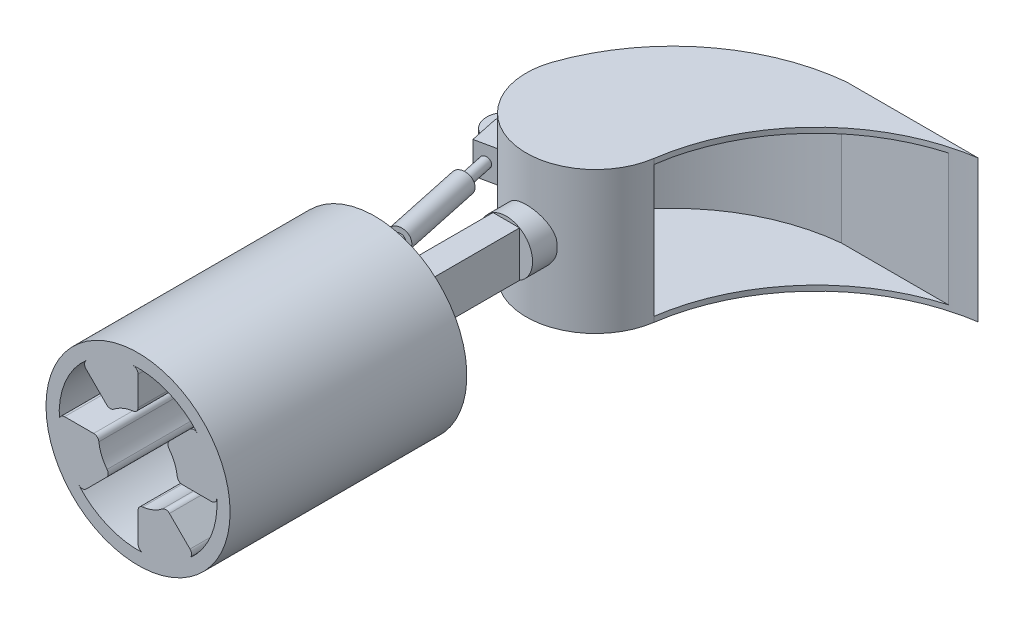
from build123d import *
from build123d.topology import SkipClean

# Parameters (mm, degrees)
BOSS_EXTRUDE1_DEPTH       = 2
BOSS_EXTRUDE2_START       = 50
BOSS_EXTRUDE2_DEPTH       = 50
BOSS_EXTRUDE3_START       = 2
BOSS_EXTRUDE3_DEPTH       = 2
SKETCH4_W                 = 9.387961781
SKETCH4_H                 = 10
SKETCH5_W                 = 10.07129112
SKETCH5_H                 = 17.27915204
BOSS_EXTRUDE4_DEPTH       = 50
BOSS_EXTRUDE5_DEPTH       = 7.5
BOSS_EXTRUDE5_DEPTH_BACK  = 7.5
CUT_EXTRUDE1_DEPTH        = 21.5
SKETCH8_R                 = 4
CUT_EXTRUDE2_DEPTH        = 21.5
SKETCH9_R                 = 35
BOSS_EXTRUDE7_DEPTH       = 90
SKETCH12_R                = 35
BOSS_EXTRUDE8_DEPTH       = 10
BOSS_EXTRUDE9_DEPTH       = 5
BOSS_EXTRUDE9_DEPTH_BACK  = 5
SKETCH13_R                = 4
BOSS_EXTRUDE10_DEPTH      = 1
BOSS_EXTRUDE10_DEPTH_BACK = 11


with BuildPart() as part:
    # Sketch1 → Boss-Extrude1 (new body)
    with BuildSketch(Plane(origin=(0, 0, 0), x_dir=(1, 0, 0), z_dir=(0, 1, 0))):
        with BuildLine():
            Line((37.497695016, 57.938362748), (87.497695016, 57.938362748))
            ThreePointArc((87.497695016, 57.938362748), (46.576317276, 37.244851113), (26.079739949, -3.775520627))
            ThreePointArc((26.079739949, -3.775520627), (-6.213319511, -25.608632381), (-24.910176653, 8.595957825))
            ThreePointArc((-24.910176653, 8.595957825), (-0.927644781, 42.400733173), (37.497695016, 57.938362748))
        make_face()
    extrude(amount=BOSS_EXTRUDE1_DEPTH)

    # Sketch2 → Boss-Extrude2 (add)
    with SkipClean():  # the faces are left unmerged after this step: merging them gives an invalid solid
        with BuildSketch(Plane.XZ.offset(BOSS_EXTRUDE2_START)):
            with BuildLine():
                Line((87.497695016, -57.938362748), (37.497695016, -57.938362748))
                ThreePointArc((37.497695016, -57.938362748), (-0.927644781, -42.400733173), (-24.910176653, -8.595957825))
                ThreePointArc((-24.910176653, -8.595957825), (-6.213319511, 25.608632381), (26.079739949, 3.775520627))
                Line((26.079739949, 3.775520627), (24.100374046, 3.488971114))
                ThreePointArc((24.100374046, 3.488971114), (-5.741749135, 23.665021983), (-23.019576731, -7.943553091))
                ThreePointArc((-23.019576731, -7.943553091), (0.27399215, -40.801176215), (37.597970133, -55.938362748))
                Line((37.597970133, -55.938362748), (78.265833112, -55.938362748))
                ThreePointArc((78.265833112, -55.938362748), (82.849368767, -57.087897202), (87.497695016, -57.938362748))
            make_face()
        extrude(amount=-BOSS_EXTRUDE2_DEPTH)

    # Sketch3 → Boss-Extrude3 (add)
    with SkipClean():  # the faces are left unmerged after this step: merging them gives an invalid solid
        with BuildSketch(Plane.XZ.offset(50).offset(BOSS_EXTRUDE3_START)):
            with BuildLine():
                Line((37.497695016, -57.938362748), (87.497695016, -57.938362748))
                ThreePointArc((87.497695016, -57.938362748), (82.849368767, -57.087897202), (78.265833112, -55.938362748))
                ThreePointArc((78.265833112, -55.938362748), (43.353130622, -33.789233028), (26.079739949, 3.775520627))
                ThreePointArc((26.079739949, 3.775520627), (-6.213319511, 25.608632381), (-24.910176653, -8.595957825))
                ThreePointArc((-24.910176653, -8.595957825), (-0.927644781, -42.400733173), (37.497695016, -57.938362748))
            make_face()
        extrude(amount=-BOSS_EXTRUDE3_DEPTH)

    # Sketch4 → Revolve1 (revolve)
    with SkipClean():  # the faces are left unmerged after this step: merging them gives an invalid solid
        with BuildSketch(Plane(origin=(0, 0, 0), x_dir=(0, 0, -1), z_dir=(1, 0, 0))):
            with Locations((-29.221177555, -30)):
                Rectangle(SKETCH4_W, SKETCH4_H)
        revolve(axis=Axis((0, -25, 24.527196664), (0, 0, 1)))

    # Sketch5 → Boss-Extrude4 (add)
    with SkipClean():  # the faces are left unmerged after this step: merging them gives an invalid solid
        with BuildSketch(Plane.XY.offset(33.915158445)):
            with Locations((0, -25)):
                Rectangle(SKETCH5_W, SKETCH5_H)
        extrude(amount=BOSS_EXTRUDE4_DEPTH)

    # Sketch6 → Boss-Extrude5 (add, two sides: drawn at the far end of the back side and taken through both)
    with SkipClean():  # the faces are left unmerged after this step: merging them gives an invalid solid
        with BuildSketch(Plane.XY.offset(-BOSS_EXTRUDE5_DEPTH_BACK)):
            Polygon((-41.351610801, -30), (-41.351610801, -20), (-26.351610801, -20), (-24.351610801, -20), (-24.351610801, -30), (-26.351610801, -30), align=None)
        extrude(amount=BOSS_EXTRUDE5_DEPTH + BOSS_EXTRUDE5_DEPTH_BACK)

    # Sketch7 → Cut-Extrude1 (cut)
    with SkipClean():  # the faces are left unmerged after this step: merging them gives an invalid solid
        with BuildSketch(Plane.XZ.offset(30)):
            with BuildLine():
                Line((-33.851610801, 7.5), (-42.709452284, 8.726443805))
                Line((-42.709452284, 8.726443805), (-44.053766645, -0.98270345))
                Line((-44.053766645, -0.98270345), (-42.206726401, -11.544313992))
                Line((-42.206726401, -11.544313992), (-33.264120107, -11.544313992))
                Line((-33.264120107, -11.544313992), (-33.851610801, -7.5))
                ThreePointArc((-33.851610801, -7.5), (-41.351610801, 0), (-33.851610801, 7.5))
            make_face()
        extrude(amount=-CUT_EXTRUDE1_DEPTH, mode=Mode.SUBTRACT)

    # Sketch8 → Cut-Extrude2 (cut)
    with SkipClean():  # the faces are left unmerged after this step: merging them gives an invalid solid
        with BuildSketch(Plane.XZ.offset(30)):
            with Locations((-33.851610801, 0)):
                Circle(SKETCH8_R)
        extrude(amount=-CUT_EXTRUDE2_DEPTH, mode=Mode.SUBTRACT)



with BuildPart() as body_2:
    # Sketch9 → Boss-Extrude7 (new body)
    with BuildSketch(Plane.XY.offset(83.915158445)):
        with Locations((0, -25)):
            Circle(SKETCH9_R)
        with BuildLine():
            Line((0, -8.118056984), (0, 2.928480088))
            ThreePointArc((0, 2.928480088), (-0.637229712, 4.392330197), (-2.142857143, 4.923371522))
            ThreePointArc((-2.142857143, 4.923371522), (11.480502971, 2.716385975), (22.674247736, -5.356209897))
            ThreePointArc((22.674247736, -5.356209897), (21.234105448, -4.667073454), (19.748417658, -5.251582342))
            Line((19.748417658, -5.251582342), (11.937336386, -13.062663614))
            ThreePointArc((11.937336386, -13.062663614), (11.355025232, -14.359025333), (11.780779366, -15.714891626))
            ThreePointArc((11.780779366, -15.714891626), (13.858192988, -19.259748515), (14.895832073, -23.235294118))
            ThreePointArc((14.895832073, -23.235294118), (15.553520688, -24.495090003), (16.881943016, -25))
            Line((16.881943016, -25), (27.928480088, -25))
            ThreePointArc((27.928480088, -25), (29.392330197, -24.362770288), (29.923371522, -22.857142857))
            ThreePointArc((29.923371522, -22.857142857), (27.716385975, -36.480502971), (19.643790103, -47.674247736))
            ThreePointArc((19.643790103, -47.674247736), (20.332926546, -46.234105448), (19.748417658, -44.748417658))
            Line((19.748417658, -44.748417658), (11.937336386, -36.937336386))
            ThreePointArc((11.937336386, -36.937336386), (10.640974667, -36.355025232), (9.285108374, -36.780779366))
            ThreePointArc((9.285108374, -36.780779366), (5.740251485, -38.858192988), (1.764705882, -39.895832073))
            ThreePointArc((1.764705882, -39.895832073), (0.504909997, -40.553520688), (0, -41.881943016))
            Line((0, -41.881943016), (0, -52.928480088))
            ThreePointArc((0, -52.928480088), (0.637229712, -54.392330197), (2.142857143, -54.923371522))
            ThreePointArc((2.142857143, -54.923371522), (-11.480502971, -52.716385975), (-22.674247736, -44.643790103))
            ThreePointArc((-22.674247736, -44.643790103), (-21.234105448, -45.332926546), (-19.748417658, -44.748417658))
            Line((-19.748417658, -44.748417658), (-11.937336386, -36.937336386))
            ThreePointArc((-11.937336386, -36.937336386), (-11.355025232, -35.640974667), (-11.780779366, -34.285108374))
            ThreePointArc((-11.780779366, -34.285108374), (-13.858192988, -30.740251485), (-14.895832073, -26.764705882))
            ThreePointArc((-14.895832073, -26.764705882), (-15.553520688, -25.504909997), (-16.881943016, -25))
            Line((-16.881943016, -25), (-27.928480088, -25))
            ThreePointArc((-27.928480088, -25), (-29.392330197, -25.637229712), (-29.923371522, -27.142857143))
            ThreePointArc((-29.923371522, -27.142857143), (-27.716385975, -13.519497029), (-19.643790103, -2.325752264))
            ThreePointArc((-19.643790103, -2.325752264), (-20.332926546, -3.765894552), (-19.748417658, -5.251582342))
            Line((-19.748417658, -5.251582342), (-11.937336386, -13.062663614))
            ThreePointArc((-11.937336386, -13.062663614), (-10.640974667, -13.644974768), (-9.285108374, -13.219220634))
            ThreePointArc((-9.285108374, -13.219220634), (-5.740251485, -11.141807012), (-1.764705882, -10.104167927))
            ThreePointArc((-1.764705882, -10.104167927), (-0.504909997, -9.446479312), (0, -8.118056984))
        make_face(mode=Mode.SUBTRACT)
    extrude(amount=BOSS_EXTRUDE7_DEPTH)


with BuildPart() as part_1:
    with SkipClean():  # the faces are left unmerged after this step: merging them gives an invalid solid
        add(part.part)

        add(body_2.part)  # Boss-Extrude8 merges body 2
        # Sketch12 → Boss-Extrude8 (add)
        with BuildSketch(Plane(origin=(0, 0, 83.915158445), x_dir=(-1, 0, 0), z_dir=(0, 0, -1))):
            with Locations((0, -25)):
                Circle(SKETCH12_R)
        extrude(amount=-BOSS_EXTRUDE8_DEPTH)

    # Sketch13 → Boss-Extrude9 (add, two sides: drawn at the far end of the back side and taken through both)
    with SkipClean():  # the faces are left unmerged after this step: merging them gives an invalid solid
        with BuildSketch(Plane(origin=(0, -25, 0), x_dir=(-1, 0, 0), z_dir=(0, -1, 0)).offset(-BOSS_EXTRUDE9_DEPTH_BACK)):
            with BuildLine():
                Line((5.03564556, -68.915158445), (17.53564556, -68.915158445))
                ThreePointArc((17.53564556, -68.915158445), (25.03564556, -76.415158445), (17.53564556, -83.915158445))
                Line((17.53564556, -83.915158445), (5.03564556, -83.915158445))
                Line((5.03564556, -83.915158445), (5.03564556, -68.915158445))
            make_face()
            with Locations((17.53564556, -76.415158445)):
                Circle(SKETCH13_R, mode=Mode.SUBTRACT)
        extrude(amount=BOSS_EXTRUDE9_DEPTH + BOSS_EXTRUDE9_DEPTH_BACK)

    # Sketch14 → Boss-Extrude10 (add, two sides: drawn at the far end of the back side and taken through both)
    with SkipClean():  # the faces are left unmerged after this step: merging them gives an invalid solid
        with BuildSketch(Plane(origin=(0, -20, 0), x_dir=(1, 0, 0), z_dir=(0, 1, 0)).offset(-BOSS_EXTRUDE10_DEPTH_BACK)):
            with BuildLine():
                Line((-37.763435172, -0.835242533), (-21.447469931, -77.250400977))
                ThreePointArc((-21.447469931, -77.250400977), (-16.700403027, -80.326982816), (-13.623821188, -75.579915912))
                Line((-13.623821188, -75.579915912), (-29.93978643, 0.835242533))
                ThreePointArc((-29.93978643, 0.835242533), (-34.686853333, 3.911824371), (-37.763435172, -0.835242533))
            make_face()
        extrude(amount=BOSS_EXTRUDE10_DEPTH + BOSS_EXTRUDE10_DEPTH_BACK)

    # Sketch15 → Cut-Revolve3 (revolve, cut)
    with SkipClean():  # the faces are left unmerged after this step: merging them gives an invalid solid
        with BuildSketch(Plane(origin=(0, -25, 0), x_dir=(-1, 0, 0), z_dir=(0, -1, 0))):
            Polygon((35.593848765, -10.996412073), (33.63793658, -10.578790807), (33.090755592, -13.141490668), (31.28077844, -21.618444914), (33.236690626, -22.036066181), (26.709197586, -52.607313883), (24.753285401, -52.189692616), (22.253765143, -63.896093902), (21.61500343, -66.887708362), (24.042512586, -67.406023783), (25.786330939, -67.778359328), (26.764287032, -67.987169961), (38.787220181, -11.678252405), (37.809264089, -11.469441772), align=None)
        revolve(axis=Axis((-31.682024394, -25, 10.16116954), (0.2088106331599759, 0, 0.9779560928177349)), mode=Mode.SUBTRACT)


solid = part_1.part
